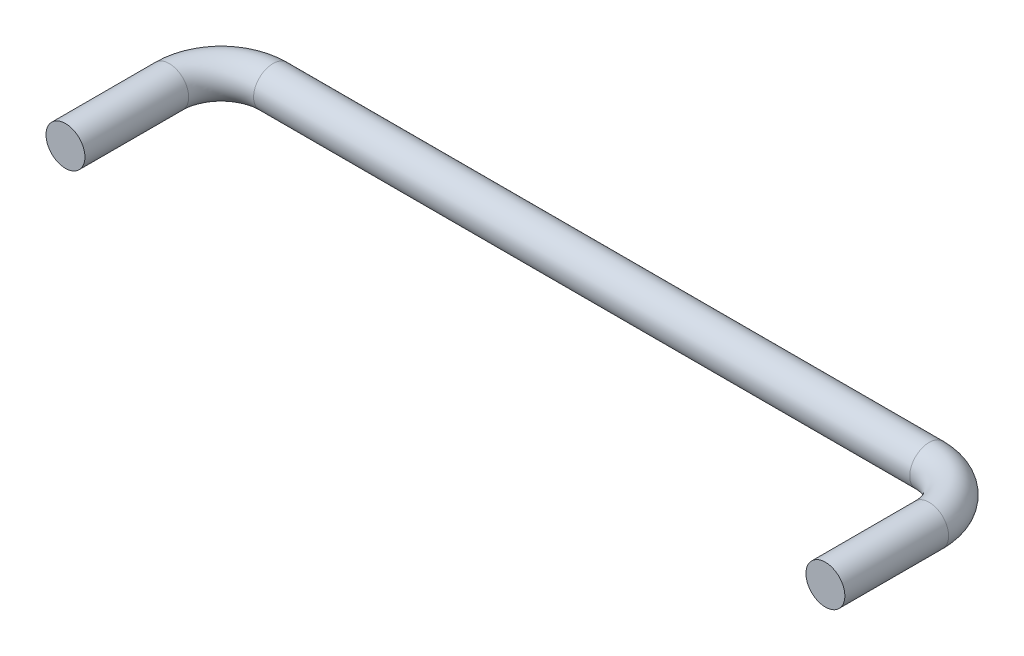
from build123d import *

# Parameters (mm, degrees)
CROQUIS2_R = 3.75


with BuildPart() as part:
    # Barrer1: sweep along a path in Croquis1
    with BuildLine(Plane(origin=(0, 0, 0), x_dir=(1, 0, 0), z_dir=(0, 1, 0))) as barrer1_path:
        Line((0, 0), (0, 20))
        ThreePointArc((0, 20), (2.928932188, 27.071067812), (10, 30))
        Line((10, 30), (136.4548, 30))
        ThreePointArc((136.4548, 30), (143.525867812, 27.071067812), (146.4548, 20))
        Line((146.4548, 20), (146.4548, 0))
    # Croquis2 → Barrer1 (sweep)
    with BuildSketch(Plane.XY):
        Circle(CROQUIS2_R)
    sweep(path=barrer1_path.line)


solid = part.part
